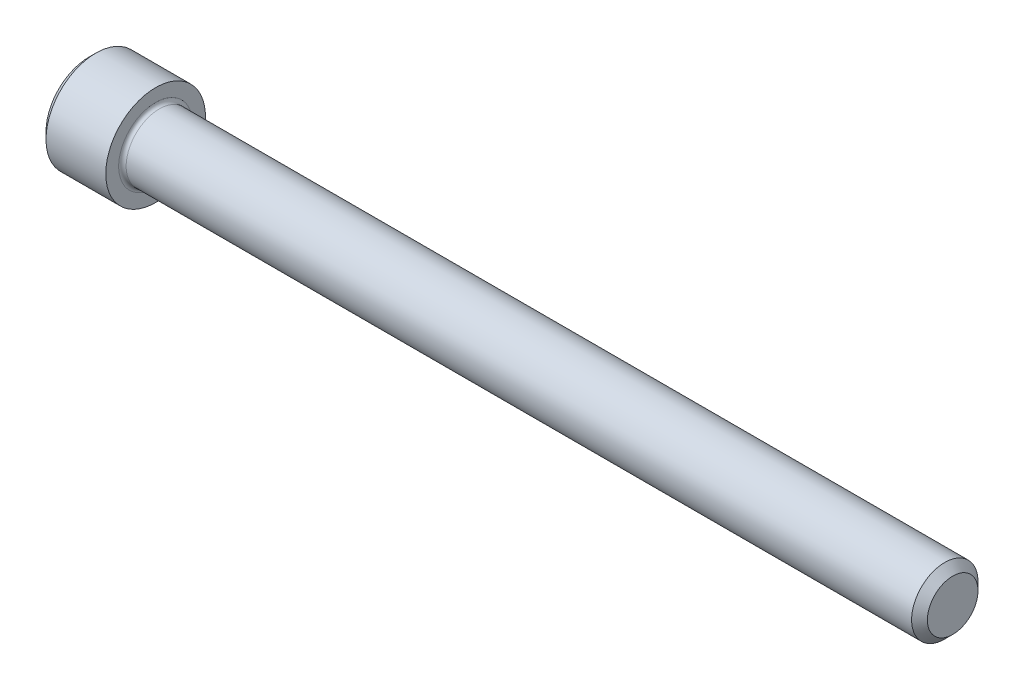
from build123d import *

# Parameters (mm, degrees)
FILLET1_R   = 0.3556
HEX_2_DEPTH = 3.048


with BuildPart() as part:
    # BodySke → Base-Revolve (revolve)
    with BuildSketch(Plane.XY):
        Polygon((0, 0), (0, 4.1275), (0.635, 4.7625), (6.35, 4.7625), (6.35, 3.175), (81.79435, 3.175), (82.55, 2.41935), (82.55, 0), align=None)
    revolve(axis=Axis((-31.75, 0, 0), (1, 0, 0)))

    # Fillet1
    fillet1_edges = [part.edges().sort_by_distance(p)[0] for p in [
        (6.35, -3.175, 0),
    ]]
    fillet(fillet1_edges, radius=FILLET1_R)

    # Sketch2 → Hex-PreBroach (revolve, cut)
    with BuildSketch(Plane.XY):
        Polygon((0, 2.38125), (3.048, 2.38125), (4.422815329, 0), (0, 0), align=None)
    revolve(axis=Axis((0, 0, 0), (1, 0, 0)), mode=Mode.SUBTRACT)

    # Sketch3 → Hex 2 (cut)
    with BuildSketch(Plane(origin=(0, 0, 0), x_dir=(0, 0.5, 0.866025404), z_dir=(-1, 0, 0))):
        Polygon((1.374815329, 2.38125), (-1.374815329, 2.38125), (-2.749630657, 0), (-1.374815329, -2.38125), (1.374815329, -2.38125), (2.749630657, 0), align=None)
    extrude(amount=-HEX_2_DEPTH, mode=Mode.SUBTRACT)


solid = part.part
